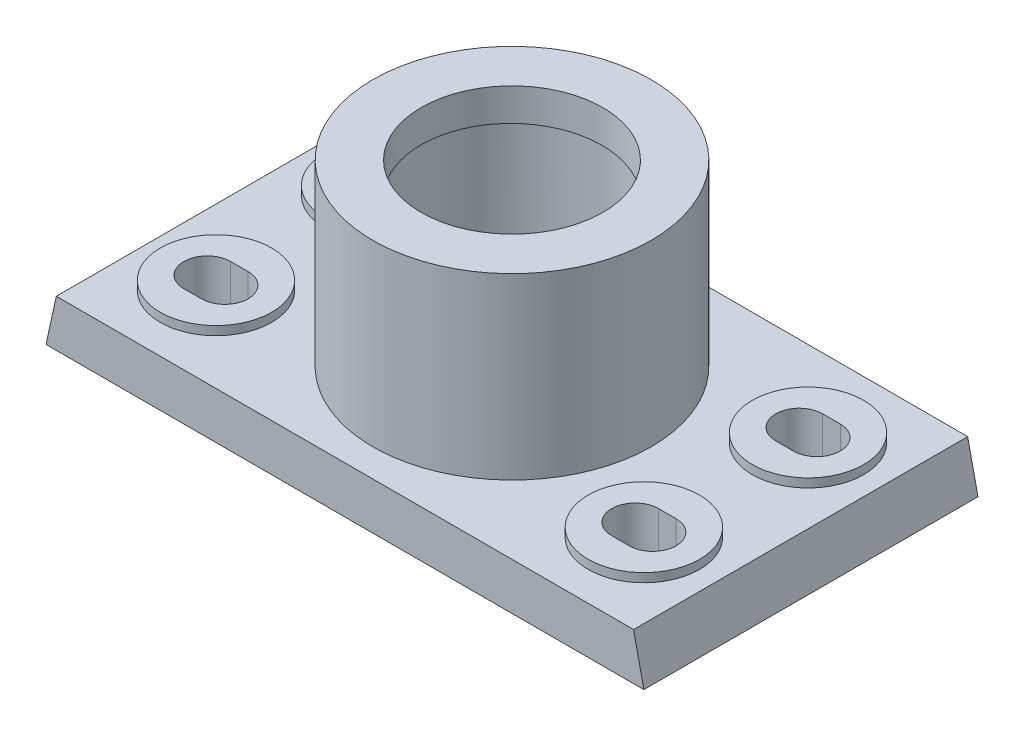
from build123d import *

# Parameters (mm, degrees)
BOSS_EXTRUDE1_DEPTH = 57
SKETCH2_W           = 85.5
SKETCH2_H           = 94
CUT_EXTRUDE1_DEPTH  = 3
SKETCH5_R           = 19
BOSS_EXTRUDE4_DEPTH = 3
CUT_EXTRUDE3_DEPTH  = 20
SKETCH7_R           = 47.5
SKETCH7_R_2         = 31
BOSS_EXTRUDE5_DEPTH = 61
SKETCH12_W          = 3
SKETCH12_H          = 37
SKETCH17_R          = 1.5
CUT_EXTRUDE4_DEPTH  = 10


with BuildPart() as part:
    # Sketch1 → Boss-Extrude1 (new body, symmetric)
    with BuildSketch(Plane.XY):
        Polygon((102, 0), (-102, 0), (-98.482758621, 16), (98.482758621, 16), align=None)
    extrude(amount=BOSS_EXTRUDE1_DEPTH, both=True)

    # Sketch2 → Cut-Extrude1 (cut)
    with BuildSketch(Plane.XZ):
        with Locations((-49.25, 0)):
            Rectangle(SKETCH2_W, SKETCH2_H)
    cut_extrude1 = extrude(amount=-CUT_EXTRUDE1_DEPTH, mode=Mode.SUBTRACT)

    # Mirror1: Cut-Extrude1 across plane
    add(cut_extrude1.mirror(Plane(origin=(0, 0, 0), x_dir=(0, 0, 1), z_dir=(1, 0, 0))), mode=Mode.SUBTRACT)

    # Sketch5 → Boss-Extrude4 (add)
    with BuildSketch(Plane(origin=(0, 16, 0), x_dir=(1, 0, 0), z_dir=(0, 1, 0))):
        with Locations((-73, 28)):
            Circle(SKETCH5_R)
        with Locations((-73, -28)):
            Circle(SKETCH5_R)
    boss_extrude4 = extrude(amount=BOSS_EXTRUDE4_DEPTH)

    # Sketch6 → Cut-Extrude3 (cut, through all)
    with BuildSketch(Plane(origin=(0, 19, 0), x_dir=(1, 0, 0), z_dir=(0, 1, 0))):
        with BuildLine():
            Line((-76, 36), (-70, 36))
            ThreePointArc((-70, 36), (-62, 28), (-70, 20))
            Line((-70, 20), (-76, 20))
            ThreePointArc((-76, 20), (-84, 28), (-76, 36))
        make_face()
        with BuildLine():
            Line((-76, -20), (-70, -20))
            ThreePointArc((-70, -20), (-62, -28), (-70, -36))
            Line((-70, -36), (-76, -36))
            ThreePointArc((-76, -36), (-84, -28), (-76, -20))
        make_face()
    cut_extrude3 = extrude(amount=-CUT_EXTRUDE3_DEPTH, mode=Mode.SUBTRACT)

    # Mirror2: Boss-Extrude4, Cut-Extrude3 across plane
    add(boss_extrude4.mirror(Plane(origin=(0, 0, 0), x_dir=(0, 0, 1), z_dir=(1, 0, 0))))
    add(cut_extrude3.mirror(Plane(origin=(0, 0, 0), x_dir=(0, 0, 1), z_dir=(1, 0, 0))), mode=Mode.SUBTRACT)

    # Sketch7 → Boss-Extrude5 (add)
    with BuildSketch(Plane(origin=(0, 16, 0), x_dir=(1, 0, 0), z_dir=(0, 1, 0))):
        Circle(SKETCH7_R)
        with Locations(Location((0, 0, 0), (0, 0, 180))):  # turned: the seam where the file's is
            Circle(SKETCH7_R_2, mode=Mode.SUBTRACT)
    extrude(amount=BOSS_EXTRUDE5_DEPTH)

    # Sketch12 → Cut-Revolve6 (revolve, cut)
    with BuildSketch(Plane.XY, mode=Mode.PRIVATE) as cut_revolve6_sk:
        with Locations((-31, 47.5)):
            Rectangle(SKETCH12_W, SKETCH12_H)
    revolve(cut_revolve6_sk.sketch.rotate(Axis((0, 0, 0), (0.010431918, 0.999945586, 0)), 180), axis=Axis((0, 0, 0), (0.010431918, 0.999945586, 0)), mode=Mode.SUBTRACT)  # turned: the seam where the file's is

    # Sketch17 → Cut-Extrude4 (cut)
    with BuildSketch(Plane(origin=(0, 16, 0), x_dir=(1, 0, 0), z_dir=(0, 1, 0))):
        with Locations(Location((-23.5, 2.202781608, 0), (0, 0, 180))):  # turned: the seam where the file's is
            Circle(SKETCH17_R)
    extrude(amount=-CUT_EXTRUDE4_DEPTH, mode=Mode.SUBTRACT)


solid = part.part
